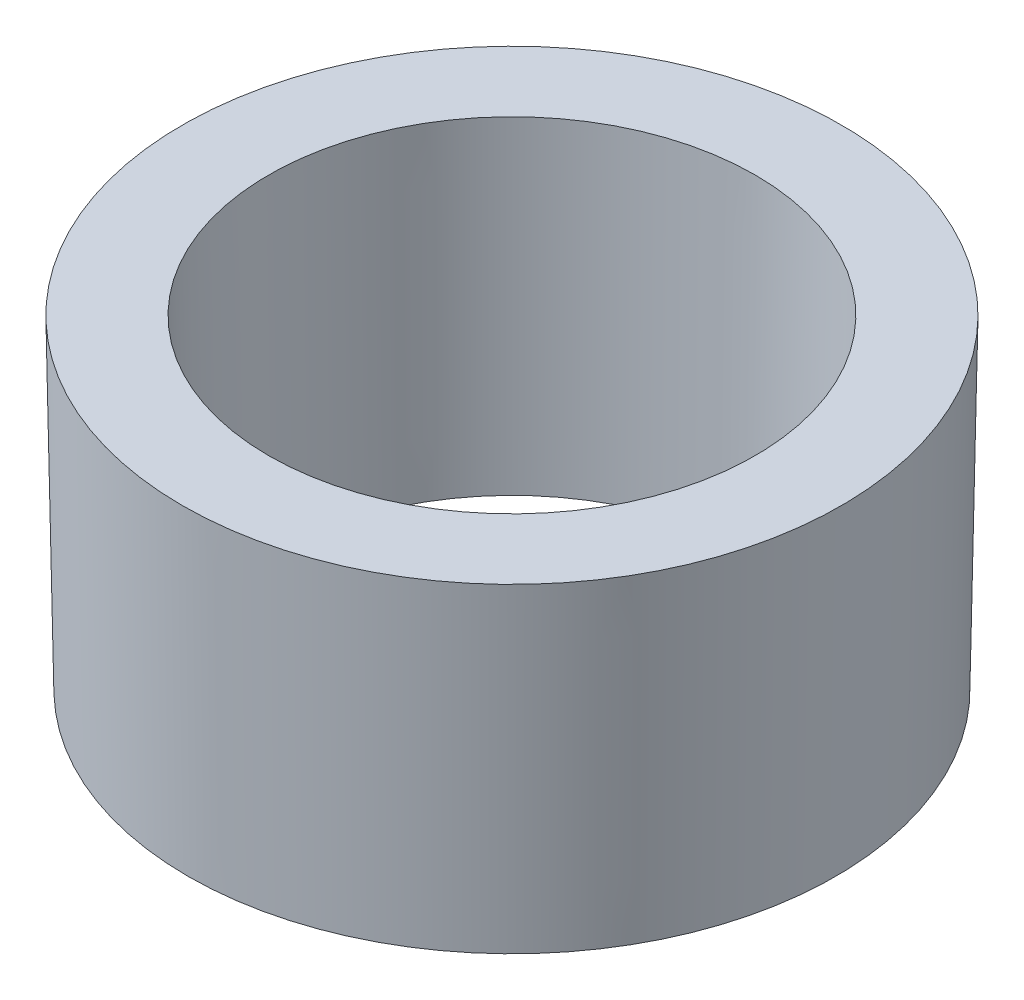
from build123d import *

# Parameters (mm, degrees)
SKETCH1_R           = 15
BOSS_EXTRUDE1_DEPTH = 15
BOSS_EXTRUDE1_TAPER = -1
SKETCH2_R           = 11
CUT_EXTRUDE1_DEPTH  = 15
CUT_EXTRUDE1_TAPER  = -1


with BuildPart() as part:
    # Sketch1 → Boss-Extrude1 (new body)
    with BuildSketch(Plane(origin=(0, 0, 0), x_dir=(1, 0, 0), z_dir=(0, 1, 0))):
        Circle(SKETCH1_R)
    extrude(amount=BOSS_EXTRUDE1_DEPTH, taper=BOSS_EXTRUDE1_TAPER)

    # Sketch2 → Cut-Extrude1 (cut)
    with BuildSketch(Plane.XZ):
        Circle(SKETCH2_R)
    extrude(amount=-CUT_EXTRUDE1_DEPTH, taper=CUT_EXTRUDE1_TAPER, mode=Mode.SUBTRACT)


solid = part.part
